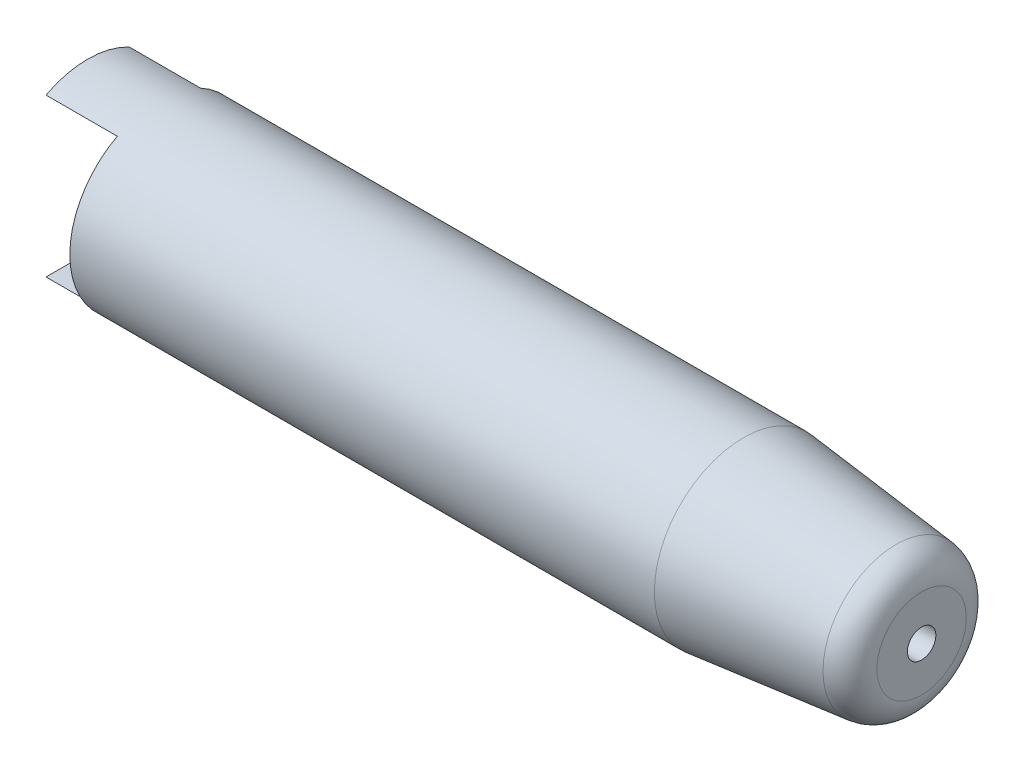
from build123d import *

# Parameters (mm, degrees)
ESQUISSE2_W             = 10
ESQUISSE2_H             = 22.1
ENL_V_MAT_EXTRU_1_DEPTH = 15


with BuildPart() as part:
    # Esquisse1 → Révolution1 (revolve)
    with BuildSketch(Plane.XY, mode=Mode.PRIVATE) as r_volution1_sk:
        with BuildLine():
            Line((56.618802154, 2), (52, 10))
            Line((52, 10), (0, 10))
            Line((0, 10), (0, 12.5))
            Line((0, 12.5), (92, 12.5))
            Line((92, 12.5), (113.418113853, 10.248865523))
            ThreePointArc((113.418113853, 10.248865523), (115.972579302, 8.947300367), (117, 6.270777941))
            Line((117, 6.270777941), (117, 2))
            Line((117, 2), (56.618802154, 2))
        make_face()
    revolve(r_volution1_sk.sketch.rotate(Axis((0, 0, 0), (1, 0, 0)), 90), axis=Axis((0, 0, 0), (1, 0, 0)))  # turned: the seam where the file's is

    # Esquisse2 → Enlèv. mat.-Extru.1 (cut, symmetric)
    with BuildSketch(Plane.XY):
        with Locations((5, 0)):
            Rectangle(ESQUISSE2_W, ESQUISSE2_H)
    extrude(amount=ENL_V_MAT_EXTRU_1_DEPTH, both=True, mode=Mode.SUBTRACT)


solid = part.part
